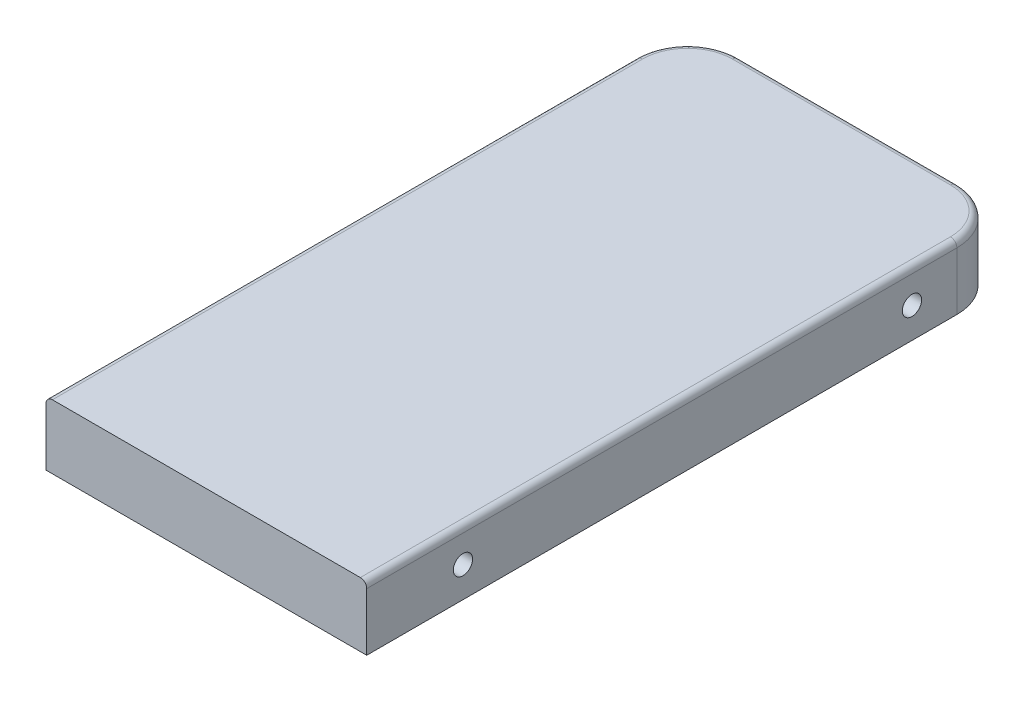
from build123d import *

# Parameters (mm, degrees)
SKETCH1_W           = 500
SKETCH1_H           = 1000
BOSS_EXTRUDE1_DEPTH = 100
SKETCH2_R           = 15
CUT_EXTRUDE1_DEPTH  = 501
FILLET1_R           = 80
FILLET2_R           = 10


with BuildPart() as part:
    # Sketch1 → Boss-Extrude1 (new body)
    with BuildSketch(Plane(origin=(0, 0, 0), x_dir=(1, 0, 0), z_dir=(0, 1, 0))):
        with Locations((250, -500)):
            Rectangle(SKETCH1_W, SKETCH1_H)
    extrude(amount=BOSS_EXTRUDE1_DEPTH)

    # Sketch2 → Cut-Extrude1 (cut, through all)
    with BuildSketch(Plane(origin=(500, 0, 0), x_dir=(0, 0, -1), z_dir=(1, 0, 0))):
        with Locations((-850, 47.419401297)):
            Circle(SKETCH2_R)
        with Locations((-150, 47.419401297)):
            Circle(SKETCH2_R)
    extrude(amount=-CUT_EXTRUDE1_DEPTH, mode=Mode.SUBTRACT)

    # Fillet1
    fillet1_edges = [part.edges().sort_by_distance(p)[0] for p in [
        (0, 50, 0),
        (500, 50, 0),
    ]]
    fillet(fillet1_edges, radius=FILLET1_R)

    # Fillet2
    fillet2_edges = [part.edges().sort_by_distance(p)[0] for p in [
        (500, 100, 540),
        (250, 100, 0),
        (0, 100, 540),
        (23.431457505, 100, 23.431457505),
        (476.568542495, 100, 23.431457505),
    ]]
    fillet(fillet2_edges, radius=FILLET2_R)


solid = part.part
